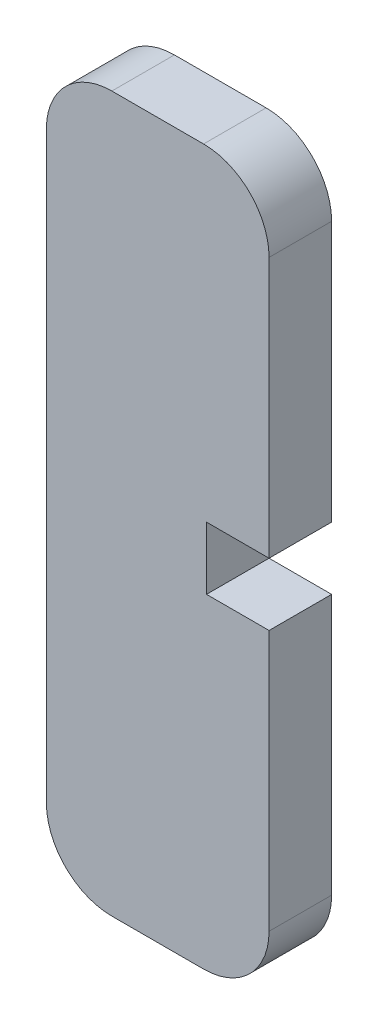
from build123d import *

# Parameters (mm, degrees)
BOSS_EXTRUDE1_DEPTH = 4.7752
SKETCH2_W           = 4.7752
SKETCH2_H           = 4.7752
CUT_EXTRUDE1_DEPTH  = 4.7752


with BuildPart() as part:
    # Sketch1 → Boss-Extrude1 (new body)
    with BuildSketch(Plane.XY):
        with BuildLine():
            Line((-4.5504, 44.7752), (-4.5504, 0.2248))
            ThreePointArc((-4.5504, 0.2248), (-3.085933906, -3.310733906), (0.4496, -4.7752))
            Line((0.4496, -4.7752), (7.4496, -4.7752))
            ThreePointArc((7.4496, -4.7752), (10.985133906, -3.310733906), (12.4496, 0.2248))
            Line((12.4496, 0.2248), (12.4496, 44.7752))
            ThreePointArc((12.4496, 44.7752), (10.985133906, 48.310733906), (7.4496, 49.7752))
            Line((7.4496, 49.7752), (0.4496, 49.7752))
            ThreePointArc((0.4496, 49.7752), (-3.085933906, 48.310733906), (-4.5504, 44.7752))
        make_face()
    extrude(amount=BOSS_EXTRUDE1_DEPTH)

    # Sketch2 → Cut-Extrude1 (cut)
    with BuildSketch(Plane(origin=(0, 0, 0), x_dir=(-1, 0, 0), z_dir=(0, 0, -1))):
        with Locations((-10.062, 22.5)):
            Rectangle(SKETCH2_W, SKETCH2_H)
    extrude(amount=-CUT_EXTRUDE1_DEPTH, mode=Mode.SUBTRACT)


solid = part.part
